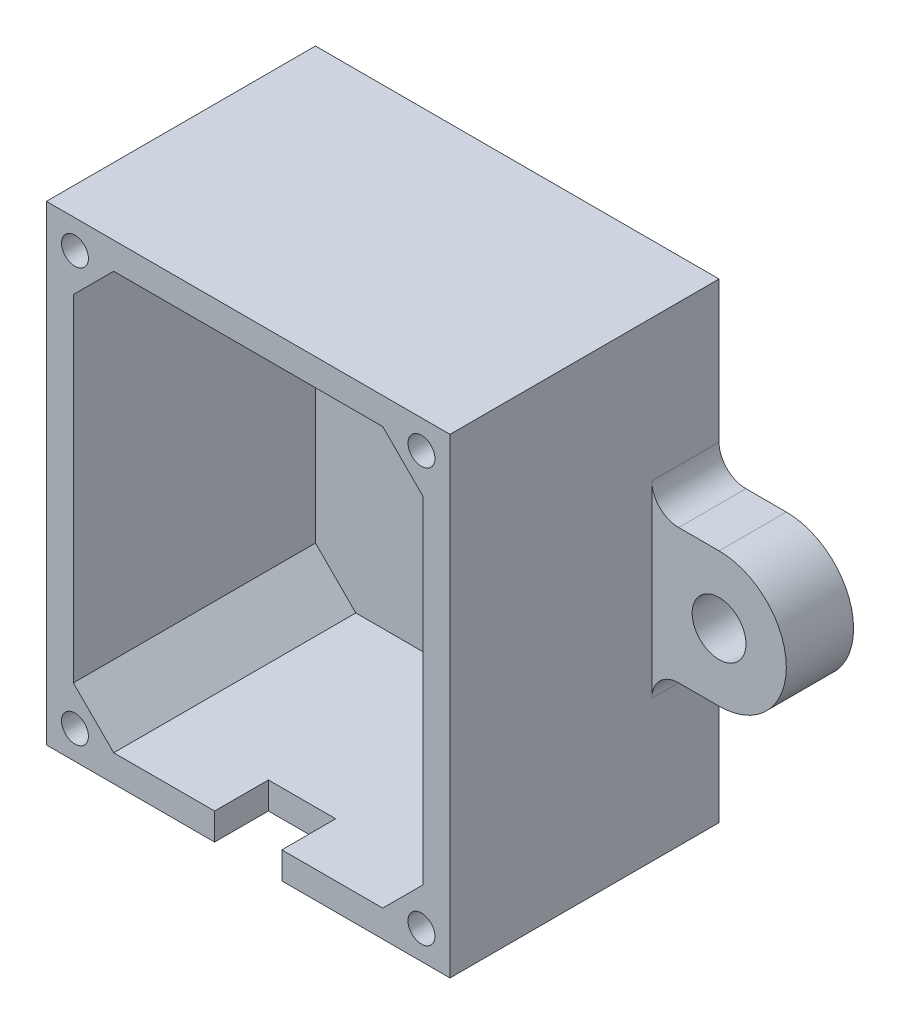
from build123d import *

# Parameters (mm, degrees)
ESQUISSE1_W             = 30
ESQUISSE1_H             = 35
BOSS_EXTRU_1_DEPTH      = 20
ENL_V_MAT_EXTRU_1_DEPTH = 18
BOSS_EXTRU_2_DEPTH      = 5
ENL_V_MAT_EXTRU_2_REACH = 7
ESQUISSE4_R             = 2
ESQUISSE5_W             = 20
ESQUISSE5_H             = 10
BOSS_EXTRU_3_DEPTH      = 5
ENL_V_MAT_EXTRU_3_REACH = 37
ESQUISSE6_W             = 5
ESQUISSE6_H             = 4
CONG_1_R                = 2
ESQUISSE7_R             = 1
ENL_V_MAT_EXTRU_4_DEPTH = 10


with BuildPart() as part:
    # Esquisse1 → Boss.-Extru.1 (new body)
    with BuildSketch(Plane.XY):
        Rectangle(ESQUISSE1_W, ESQUISSE1_H)
    extrude(amount=BOSS_EXTRU_1_DEPTH)

    # Esquisse2 → Enlèv. mat.-Extru.1 (cut)
    with BuildSketch(Plane.XY.offset(20)):
        Polygon((-10, 15.5), (10, 15.5), (13, 12.5), (13, -12.5), (10, -15.5), (-10, -15.5), (-13, -12.5), (-13, 12.5), align=None)
    extrude(amount=-ENL_V_MAT_EXTRU_1_DEPTH, mode=Mode.SUBTRACT)

    # Esquisse3 → Boss.-Extru.2 (add)
    with BuildSketch(Plane(origin=(0, 0, 0), x_dir=(-1, 0, 0), z_dir=(0, 0, -1))):
        with BuildLine():
            Line((-15, 5), (-20, 5))
            ThreePointArc((-20, 5), (-25, 0), (-20, -5))
            Line((-20, -5), (-15, -5))
            Line((-15, -5), (-15, 5))
        make_face()
        with BuildLine():
            Line((15, 5), (15, -5))
            Line((15, -5), (20, -5))
            ThreePointArc((20, -5), (25, 0), (20, 5))
            Line((20, 5), (15, 5))
        make_face()
    extrude(amount=-BOSS_EXTRU_2_DEPTH)

    # Esquisse4 → Enlèv. mat.-Extru.2 (cut, up to next)
    with BuildSketch(Plane.XY.offset(5), mode=Mode.PRIVATE) as enl_v_mat_extru_2_sk1:
        with Locations((-20, 0)):
            Circle(ESQUISSE4_R)
    enl_v_mat_extru_2_tool1 = extrude(enl_v_mat_extru_2_sk1.sketch, amount=-ENL_V_MAT_EXTRU_2_REACH, mode=Mode.PRIVATE) & part.part
    add(enl_v_mat_extru_2_tool1.solids().sort_by_distance((-20, 0, 5))[0], mode=Mode.SUBTRACT)
    # Esquisse4 → Enlèv. mat.-Extru.2 (cut, up to next)
    with BuildSketch(Plane.XY.offset(5), mode=Mode.PRIVATE) as enl_v_mat_extru_2_sk2:
        with Locations((20, 0)):
            Circle(ESQUISSE4_R)
    enl_v_mat_extru_2_tool2 = extrude(enl_v_mat_extru_2_sk2.sketch, amount=-ENL_V_MAT_EXTRU_2_REACH, mode=Mode.PRIVATE) & part.part
    add(enl_v_mat_extru_2_tool2.solids().sort_by_distance((20, 0, 5))[0], mode=Mode.SUBTRACT)

    # Esquisse5 → Boss.-Extru.3 (add)
    with BuildSketch(Plane.XY.offset(2)):
        with Locations((0, 10.5)):
            Rectangle(ESQUISSE5_W, ESQUISSE5_H)
    extrude(amount=BOSS_EXTRU_3_DEPTH)

    # Esquisse6 → Enlèv. mat.-Extru.3 (cut, up to next)
    with BuildSketch(Plane.XZ.offset(17.5), mode=Mode.PRIVATE) as enl_v_mat_extru_3_sk1:
        with Locations((0, 18)):
            Rectangle(ESQUISSE6_W, ESQUISSE6_H)
    enl_v_mat_extru_3_tool1 = extrude(enl_v_mat_extru_3_sk1.sketch, amount=-ENL_V_MAT_EXTRU_3_REACH, mode=Mode.PRIVATE) & part.part
    add(enl_v_mat_extru_3_tool1.solids().sort_by_distance((0, -17.5, 18))[0], mode=Mode.SUBTRACT)

    # Congé1
    cong_1_edges = [part.edges().sort_by_distance(p)[0] for p in [
        (15, -5, 2.5),
        (15, 5, 2.5),
        (-15, 5, 2.5),
        (-15, -5, 2.5),
    ]]
    fillet(cong_1_edges, radius=CONG_1_R)

    # Esquisse7 → Enlèv. mat.-Extru.4 (cut)
    with BuildSketch(Plane.XY.offset(20)):
        with Locations((-12.878679656, 15.378679656)):
            Circle(ESQUISSE7_R)
        with Locations((-12.878679656, -15.378679656)):
            Circle(ESQUISSE7_R)
        with Locations((12.878679656, -15.378679656)):
            Circle(ESQUISSE7_R)
        with Locations((12.878679656, 15.378679656)):
            Circle(ESQUISSE7_R)
    extrude(amount=-ENL_V_MAT_EXTRU_4_DEPTH, mode=Mode.SUBTRACT)


solid = part.part
